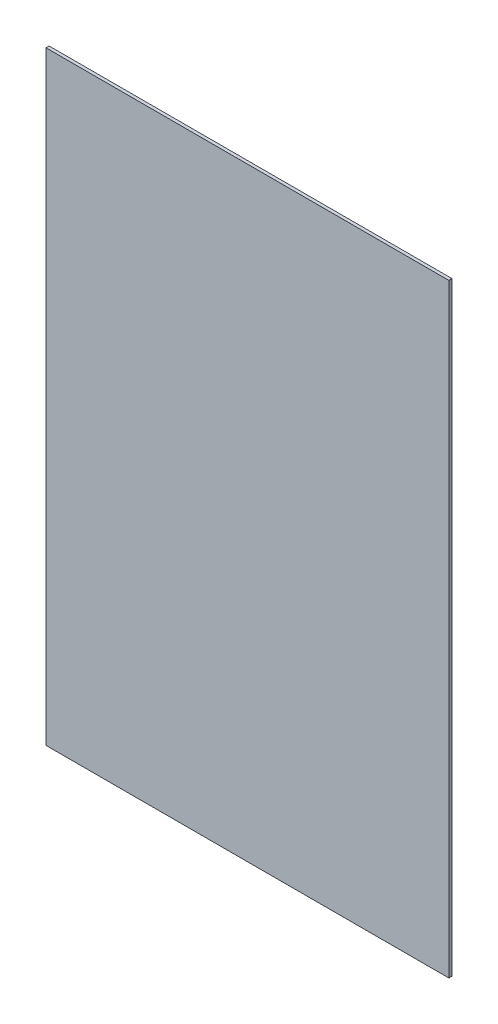
from build123d import *

# Parameters (mm, degrees)
SKETCH1_W      = 609.6
SKETCH1_H      = 914.4
EXTRUDE1_DEPTH = 4.7625


with BuildPart() as part:
    # Sketch1 → Extrude1 (new body)
    with BuildSketch(Plane.XY):
        with Locations((304.8, 457.2)):
            Rectangle(SKETCH1_W, SKETCH1_H)
    extrude(amount=EXTRUDE1_DEPTH)


solid = part.part
